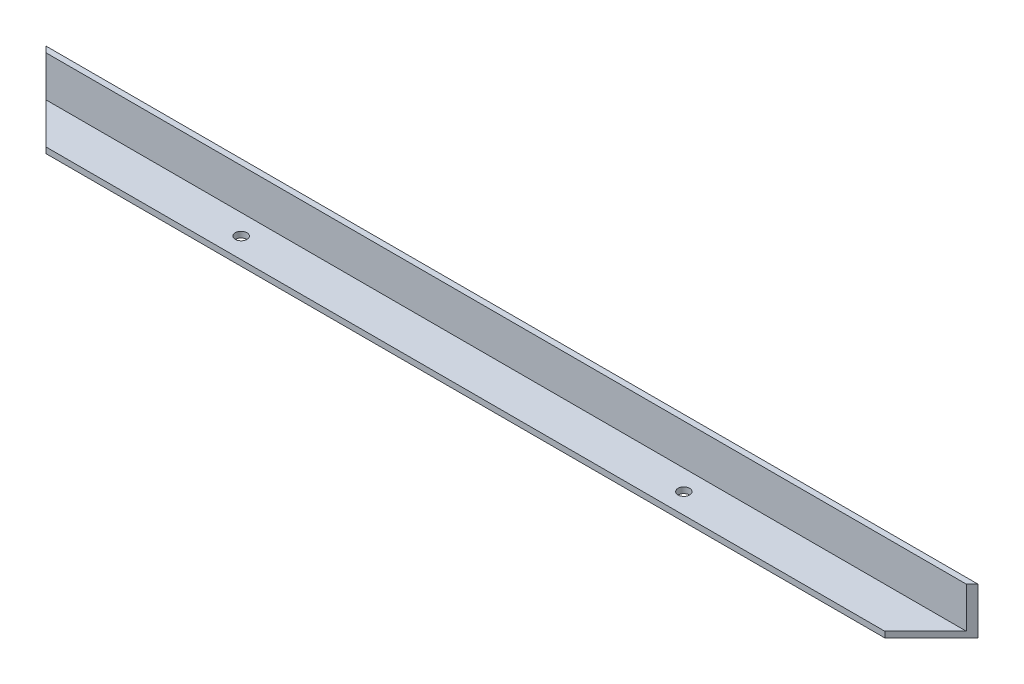
from build123d import *

# Parameters (mm, degrees)
SKETCH1_W           = 508
SKETCH1_H           = 25.4
BOSS_EXTRUDE1_DEPTH = 3.175
SKETCH2_W           = 508
SKETCH2_H           = 3.175
BOSS_EXTRUDE2_DEPTH = 22.225
CUT_EXTRUDE4_DEPTH  = 25.4
SKETCH6_R           = 3.175
CUT_EXTRUDE5_DEPTH  = 3.175
CUT_EXTRUDE6_DEPTH  = 25.4


with BuildPart() as part:
    # Sketch1 → Boss-Extrude1 (new body)
    with BuildSketch(Plane(origin=(0, 0, 0), x_dir=(1, 0, 0), z_dir=(0, 1, 0))):
        with Locations((-254, -12.7)):
            Rectangle(SKETCH1_W, SKETCH1_H)
    extrude(amount=BOSS_EXTRUDE1_DEPTH)

    # Sketch2 → Boss-Extrude2 (add)
    with BuildSketch(Plane(origin=(0, 3.175, 0), x_dir=(1, 0, 0), z_dir=(0, 1, 0))):
        with Locations((-254, -1.5875)):
            Rectangle(SKETCH2_W, SKETCH2_H)
    extrude(amount=BOSS_EXTRUDE2_DEPTH)

    # Sketch3 → Cut-Extrude4 (cut)
    with BuildSketch(Plane(origin=(0, 25.4, 0), x_dir=(1, 0, 0), z_dir=(0, 1, 0))):
        Polygon((0, 0), (-52.33160776, -52.33160776), (49.536132654, -29.784007044), align=None)
    extrude(amount=-CUT_EXTRUDE4_DEPTH, mode=Mode.SUBTRACT)

    # Sketch6 → Cut-Extrude5 (cut)
    with BuildSketch(Plane(origin=(0, 3.175, 0), x_dir=(1, 0, 0), z_dir=(0, 1, 0))):
        with Locations((-146.05, -14.2875)):
            Circle(SKETCH6_R)
        with Locations((-387.35, -14.2875)):
            Circle(SKETCH6_R)
    extrude(amount=-CUT_EXTRUDE5_DEPTH, mode=Mode.SUBTRACT)

    # Sketch7 → Cut-Extrude6 (cut)
    with BuildSketch(Plane(origin=(0, 25.4, 0), x_dir=(1, 0, 0), z_dir=(0, 1, 0))):
        Polygon((-508, 0), (-469.606769631, -38.393230369), (-537.121608827, -29.121608827), align=None)
    extrude(amount=-CUT_EXTRUDE6_DEPTH, mode=Mode.SUBTRACT)


solid = part.part
